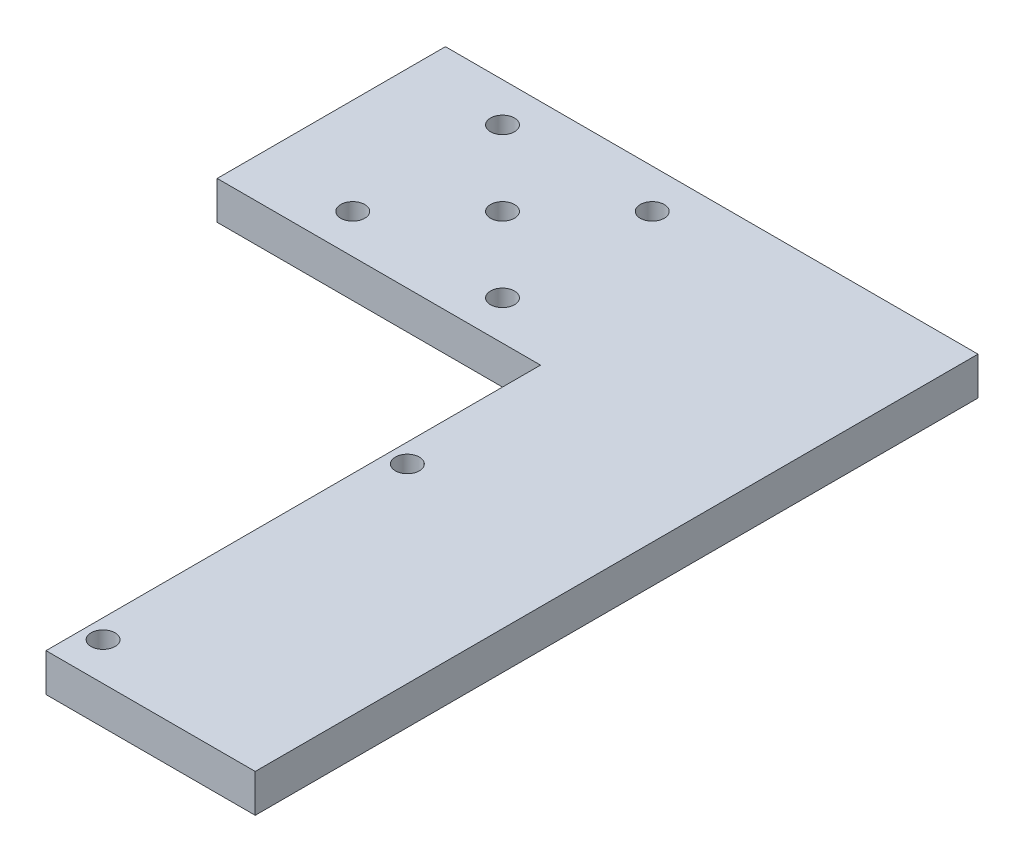
from build123d import *

# Parameters (mm, degrees)
SKETCH1_R           = 2
BOSS_EXTRUDE1_DEPTH = 6.35


with BuildPart() as part:
    # Sketch1 → Boss-Extrude1 (new body)
    with BuildSketch(Plane(origin=(0, 0, 0), x_dir=(1, 0, 0), z_dir=(0, 1, 0))):
        Polygon((0, 38.1), (0, 0), (53.975, 0), (53.975, -82.55), (88.9, -82.55), (88.9, 0), (88.9, 38.1), (53.975, 38.1), align=None)
        with Locations((57.15, -76.2)):
            Circle(SKETCH1_R, mode=Mode.SUBTRACT)
        with Locations((57.15, -25.4)):
            Circle(SKETCH1_R, mode=Mode.SUBTRACT)
        with Locations((16.075, 6.55)):
            Circle(SKETCH1_R, mode=Mode.SUBTRACT)
        with Locations((41.075, 6.55)):
            Circle(SKETCH1_R, mode=Mode.SUBTRACT)
        with Locations((16.075, 31.55)):
            Circle(SKETCH1_R, mode=Mode.SUBTRACT)
        with Locations((28.575, 19.05)):
            Circle(SKETCH1_R, mode=Mode.SUBTRACT)
        with Locations((41.075, 31.55)):
            Circle(SKETCH1_R, mode=Mode.SUBTRACT)
    extrude(amount=BOSS_EXTRUDE1_DEPTH)


solid = part.part
